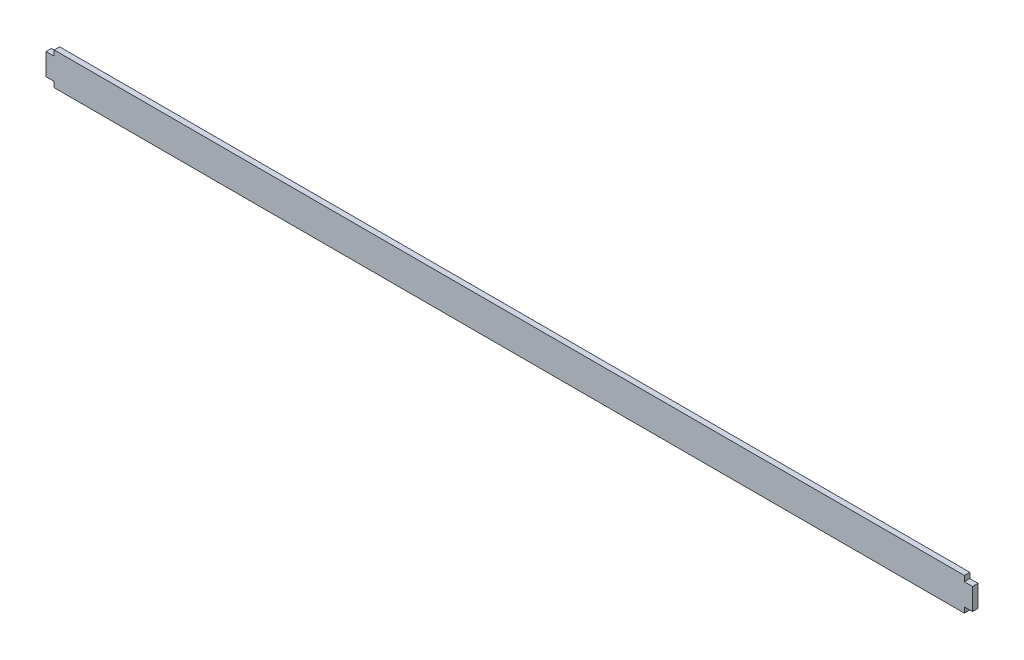
from build123d import *

# Parameters (mm, degrees)
BOSS_EXTRUDE1_DEPTH = 3.175


with BuildPart() as part:
    # Sketch1 → Boss-Extrude1 (new body)
    with BuildSketch(Plane.XY):
        Polygon((530.225, 15.875), (530.225, 19.05), (0, 19.05), (0, 15.875), (-4.7625, 15.875), (-4.7625, 3.175), (0, 3.175), (0, 0), (530.225, 0), (530.225, 3.175), (534.9875, 3.175), (534.9875, 15.875), align=None)
    extrude(amount=BOSS_EXTRUDE1_DEPTH)


solid = part.part
